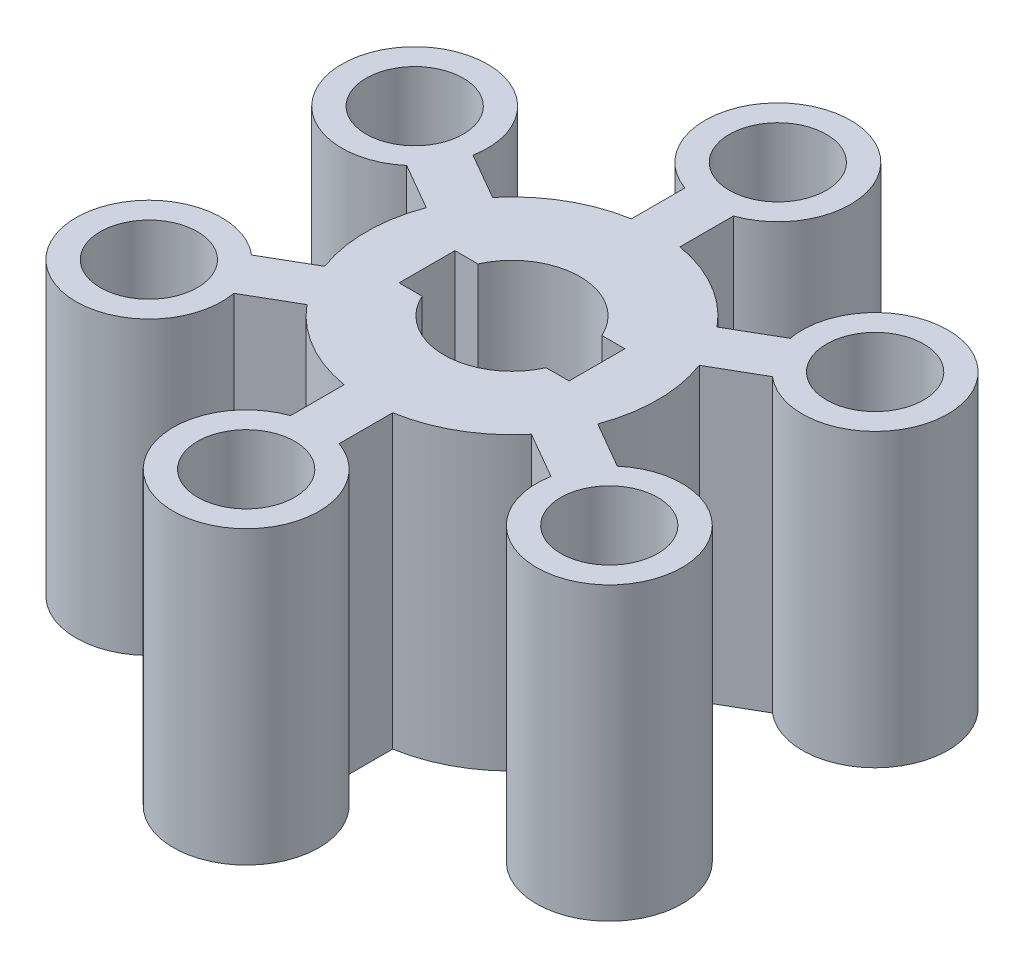
from build123d import *

# Parameters (mm, degrees)
SKETCH1_R           = 20
BOSS_EXTRUDE1_DEPTH = 120


with BuildPart() as part:
    # Sketch1 → Boss-Extrude1 (new body)
    with BuildSketch(Plane(origin=(0, 0, 0), x_dir=(1, 0, 0), z_dir=(0, 1, 0))):
        with BuildLine():
            Line((-10, 81.215728753), (-10, 59.160797831))
            ThreePointArc((-10, 59.160797831), (-30, 51.961524227), (-46.23475383, 38.240652953))
            Line((-46.23475383, 38.240652953), (-65.334884287, 49.268118414))
            ThreePointArc((-65.334884287, 49.268118414), (-120.810543828, 69.75), (-75.334884287, 31.947610338))
            Line((-75.334884287, 31.947610338), (-56.23475383, 20.920144878))
            ThreePointArc((-56.23475383, 20.920144878), (-60, 0), (-56.23475383, -20.920144878))
            Line((-56.23475383, -20.920144878), (-75.334884287, -31.947610338))
            ThreePointArc((-75.334884287, -31.947610338), (-120.810543828, -69.75), (-65.334884287, -49.268118414))
            Line((-65.334884287, -49.268118414), (-46.23475383, -38.240652953))
            ThreePointArc((-46.23475383, -38.240652953), (-30, -51.961524227), (-10, -59.160797831))
            Line((-10, -59.160797831), (-10, -81.215728753))
            ThreePointArc((-10, -81.215728753), (0, -139.5), (10, -81.215728753))
            Line((10, -81.215728753), (10, -59.160797831))
            ThreePointArc((10, -59.160797831), (30, -51.961524227), (46.23475383, -38.240652953))
            Line((46.23475383, -38.240652953), (65.334884287, -49.268118414))
            ThreePointArc((65.334884287, -49.268118414), (120.810543828, -69.75), (75.334884287, -31.947610338))
            Line((75.334884287, -31.947610338), (56.23475383, -20.920144878))
            ThreePointArc((56.23475383, -20.920144878), (60, 0), (56.23475383, 20.920144878))
            Line((56.23475383, 20.920144878), (75.334884287, 31.947610338))
            ThreePointArc((75.334884287, 31.947610338), (120.810543828, 69.75), (65.334884287, 49.268118414))
            Line((65.334884287, 49.268118414), (46.23475383, 38.240652953))
            ThreePointArc((46.23475383, 38.240652953), (30, 51.961524227), (10, 59.160797831))
            Line((10, 59.160797831), (10, 81.215728753))
            ThreePointArc((10, 81.215728753), (0, 139.5), (-10, 81.215728753))
        make_face()
        with Locations((0, 109.5)):
            Circle(SKETCH1_R, mode=Mode.SUBTRACT)
        with Locations((94.829781714, 54.75)):
            Circle(SKETCH1_R, mode=Mode.SUBTRACT)
        with Locations((94.829781714, -54.75)):
            Circle(SKETCH1_R, mode=Mode.SUBTRACT)
        with Locations((0, -109.5)):
            Circle(SKETCH1_R, mode=Mode.SUBTRACT)
        with Locations((-94.829781714, -54.75)):
            Circle(SKETCH1_R, mode=Mode.SUBTRACT)
        with Locations((-94.829781714, 54.75)):
            Circle(SKETCH1_R, mode=Mode.SUBTRACT)
        with BuildLine():
            Line((-35, 11.5), (-35, -11.5))
            Line((-35, -11.5), (-25.529394822, -11.5))
            ThreePointArc((-25.529394822, -11.5), (0, -28), (25.529394822, -11.5))
            Line((25.529394822, -11.5), (35, -11.5))
            Line((35, -11.5), (35, 11.5))
            Line((35, 11.5), (25.529394822, 11.5))
            ThreePointArc((25.529394822, 11.5), (0, 28), (-25.529394822, 11.5))
            Line((-25.529394822, 11.5), (-35, 11.5))
        make_face(mode=Mode.SUBTRACT)
    extrude(amount=BOSS_EXTRUDE1_DEPTH)


solid = part.part
